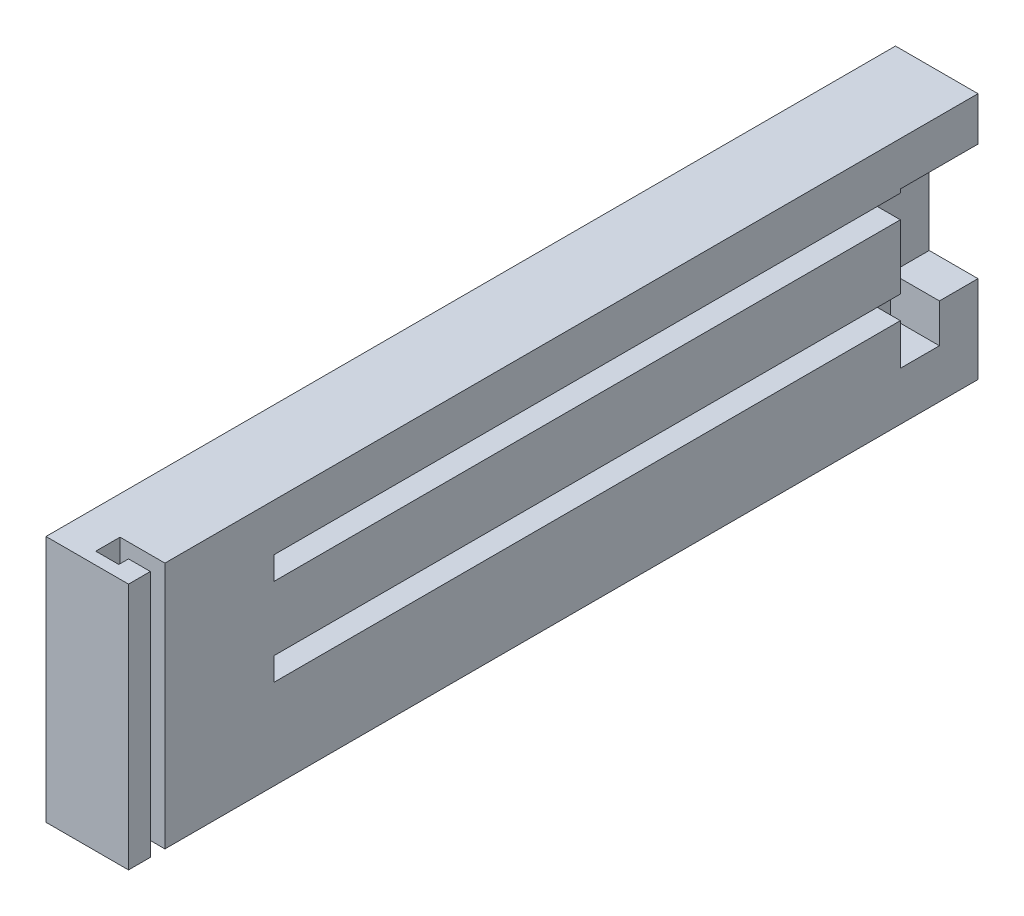
from build123d import *

# Parameters (mm, degrees)
SKETCH1_W           = 175
SKETCH1_H           = 51
BOSS_EXTRUDE1_DEPTH = 17
CUT_EXTRUDE3_DEPTH  = 52
SKETCH7_W           = 4.75
SKETCH7_H           = 4.75
CUT_EXTRUDE5_DEPTH  = 145
SKETCH10_W          = 10.05
SKETCH10_H          = 24
CUT_EXTRUDE6_DEPTH  = 16
SKETCH11_W          = 10.05
SKETCH11_H          = 8.05
CUT_EXTRUDE7_DEPTH  = 8


with BuildPart() as part:
    # Sketch1 → Boss-Extrude1 (new body)
    with BuildSketch(Plane(origin=(0, 0, 0), x_dir=(0, 0, -1), z_dir=(1, 0, 0))):
        with Locations((22.937921078, 5.057266603)):
            Rectangle(SKETCH1_W, SKETCH1_H)
    extrude(amount=BOSS_EXTRUDE1_DEPTH)

    # Sketch6 → Cut-Extrude3 (cut, through all)
    with BuildSketch(Plane(origin=(0, 30.557266603, 0), x_dir=(1, 0, 0), z_dir=(0, 1, 0))):
        Polygon((12.5, -60.062078922), (17, -60.062078922), (17, -57.062078922), (14.5, -57.062078922), (7.75, -57.062078922), (7.75, -62.062078922), (12.5, -62.062078922), align=None)
    extrude(amount=-CUT_EXTRUDE3_DEPTH, mode=Mode.SUBTRACT)

    # Sketch7 → Cut-Extrude5 (cut)
    with BuildSketch(Plane(origin=(0, 0, -110.437921078), x_dir=(-1, 0, 0), z_dir=(0, 0, -1))):
        with Locations((-14.625, 0.432266603)):
            Rectangle(SKETCH7_W, SKETCH7_H)
        with Locations((-14.625, 18.432266603)):
            Rectangle(SKETCH7_W, SKETCH7_H)
    extrude(amount=-CUT_EXTRUDE5_DEPTH, mode=Mode.SUBTRACT)

    # Sketch10 → Cut-Extrude6 (cut)
    with BuildSketch(Plane(origin=(0, 0, -110.437921078), x_dir=(-1, 0, 0), z_dir=(0, 0, -1))):
        with Locations((-11.975, 9.557266603)):
            Rectangle(SKETCH10_W, SKETCH10_H)
    extrude(amount=-CUT_EXTRUDE6_DEPTH, mode=Mode.SUBTRACT)

    # Sketch11 → Cut-Extrude7 (cut)
    with BuildSketch(Plane(origin=(0, -2.442733397, 0), x_dir=(1, 0, 0), z_dir=(0, 1, 0))):
        with Locations((11.975, 98.462921078)):
            Rectangle(SKETCH11_W, SKETCH11_H)
    extrude(amount=-CUT_EXTRUDE7_DEPTH, mode=Mode.SUBTRACT)


solid = part.part
